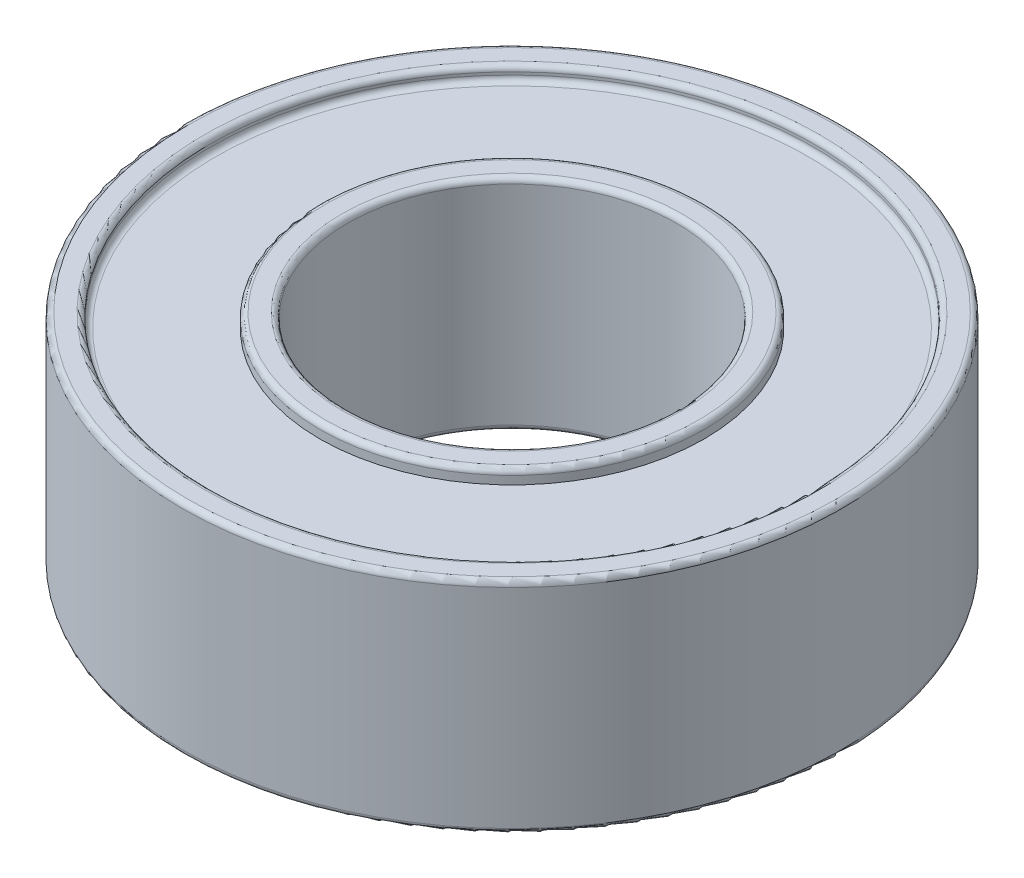
from build123d import *

# Parameters (mm, degrees)
SKETCH1_R           = 6
SKETCH1_R_2         = 3
BOSS_EXTRUDE1_DEPTH = 4
SKETCH2_R           = 5.5
SKETCH2_R_2         = 3.5
CUT_EXTRUDE1_DEPTH  = 0.25
FILLET1_R           = 0.1


with BuildPart() as part:
    # Sketch1 → Boss-Extrude1 (new body)
    with BuildSketch(Plane(origin=(0, 0, 0), x_dir=(1, 0, 0), z_dir=(0, 1, 0))):
        Circle(SKETCH1_R)
        Circle(SKETCH1_R_2, mode=Mode.SUBTRACT)
    extrude(amount=BOSS_EXTRUDE1_DEPTH)

    # Sketch2 → Cut-Extrude1 (cut)
    with BuildSketch(Plane(origin=(0, 4, 0), x_dir=(1, 0, 0), z_dir=(0, 1, 0))):
        Circle(SKETCH2_R)
        Circle(SKETCH2_R_2, mode=Mode.SUBTRACT)
    cut_extrude1 = extrude(amount=-CUT_EXTRUDE1_DEPTH, mode=Mode.SUBTRACT)

    # Mirror1: Cut-Extrude1 across plane
    add(cut_extrude1.mirror(Plane.ZX.offset(2)), mode=Mode.SUBTRACT)

    # Fillet1
    fillet1_edges = [part.edges().sort_by_distance(p)[0] for p in [
        (-5.5, 3.75, 0),
        (-5.5, 4, 0),
        (-3.5, 4, 0),
        (-5.5, 0.25, 0),
        (-3.5, 0, 0),
        (-6, 0, 0),
        (-6, 4, 0),
        (-3, 0, 0),
        (-3, 4, 0),
    ]]
    fillet(fillet1_edges, radius=FILLET1_R)


solid = part.part
